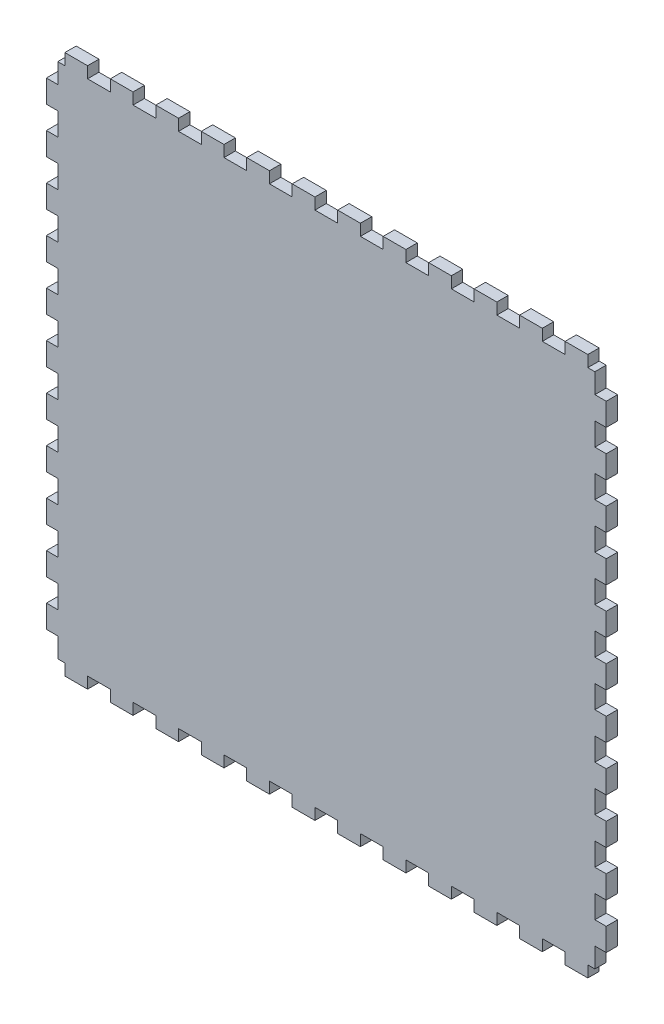
from build123d import *

# Parameters (mm, degrees)
BOSS_EXTRUDE1_DEPTH = 5.715


with BuildPart() as part:
    # Model → Boss-Extrude1 (new body)
    with BuildSketch(Plane.XY):
        Polygon((584.688856535, 28.575245224), (588.246340911, 28.575245224), (588.246340911, 22.860238699), (599.673519312, 22.860238699), (599.673519312, 28.575245224), (611.104241025, 28.575245224), (611.104241025, 22.860238699), (622.534962737, 22.860238699), (622.534962737, 28.575245224), (633.965684449, 28.575245224), (633.965684449, 22.860238699), (645.396406161, 22.860238699), (645.396406161, 28.575245224), (656.823584562, 28.575245224), (656.823584562, 22.860238699), (668.254306275, 22.860238699), (668.254306275, 28.575245224), (679.685027987, 28.575245224), (679.685027987, 22.860238699), (691.115749699, 22.860238699), (691.115749699, 28.575245224), (702.546471411, 28.575245224), (702.546471411, 22.860238699), (713.973649812, 22.860238699), (713.973649812, 28.575245224), (725.404371525, 28.575245224), (725.404371525, 22.860238699), (736.835093237, 22.860238699), (736.835093237, 28.575245224), (748.265814949, 28.575245224), (748.265814949, 22.860238699), (759.696536661, 22.860238699), (759.696536661, 28.575245224), (771.123715063, 28.575245224), (771.123715063, 22.860238699), (782.554436775, 22.860238699), (782.554436775, 28.575245224), (793.985158487, 28.575245224), (793.985158487, 22.860238699), (805.415880199, 22.860238699), (805.415880199, 28.575245224), (816.846601911, 28.575245224), (816.846601911, 22.860238699), (828.273780313, 22.860238699), (828.273780313, 28.575245224), (839.704502025, 28.575245224), (839.704502025, 22.860238699), (851.135223737, 22.860238699), (851.135223737, 28.575245224), (854.689164803, 28.575245224), (854.689164803, 38.560083395), (860.404525659, 38.560083395), (860.404525659, 49.990096445), (854.689164803, 49.990096445), (854.689164803, 61.420109495), (860.404525659, 61.420109495), (860.404525659, 72.850122545), (854.689164803, 72.850122545), (854.689164803, 84.280135595), (860.404525659, 84.280135595), (860.404525659, 95.710148645), (854.689164803, 95.710148645), (854.689164803, 107.140161695), (860.404525659, 107.140161695), (860.404525659, 118.570174745), (854.689164803, 118.570174745), (854.689164803, 130.000187795), (860.404525659, 130.000187795), (860.404525659, 141.430200846), (854.689164803, 141.430200846), (854.689164803, 152.860213896), (860.404525659, 152.860213896), (860.404525659, 164.290226946), (854.689164803, 164.290226946), (854.689164803, 175.720239996), (860.404525659, 175.720239996), (860.404525659, 187.150253046), (854.689164803, 187.150253046), (854.689164803, 198.580266096), (860.404525659, 198.580266096), (860.404525659, 210.010279146), (854.689164803, 210.010279146), (854.689164803, 221.440292196), (860.404525659, 221.440292196), (860.404525659, 232.870305246), (854.689164803, 232.870305246), (854.689164803, 244.300318296), (860.404525659, 244.300318296), (860.404525659, 255.730331346), (854.689164803, 255.730331346), (854.689164803, 267.160344396), (860.404525659, 267.160344396), (860.404525659, 278.590357446), (854.689164803, 278.590357446), (854.689164803, 288.575408216), (851.135223737, 288.575408216), (851.135223737, 294.290414741), (839.704502025, 294.290414741), (839.704502025, 288.575408216), (828.273780313, 288.575408216), (828.273780313, 294.290414741), (816.846601911, 294.290414741), (816.846601911, 288.575408216), (805.415880199, 288.575408216), (805.415880199, 294.290414741), (793.985158487, 294.290414741), (793.985158487, 288.575408216), (782.554436775, 288.575408216), (782.554436775, 294.290414741), (771.123715063, 294.290414741), (771.123715063, 288.575408216), (759.696536661, 288.575408216), (759.696536661, 294.290414741), (748.265814949, 294.290414741), (748.265814949, 288.575408216), (736.835093237, 288.575408216), (736.835093237, 294.290414741), (725.404371525, 294.290414741), (725.404371525, 288.575408216), (713.973649812, 288.575408216), (713.973649812, 294.290414741), (702.546471411, 294.290414741), (702.546471411, 288.575408216), (691.115749699, 288.575408216), (691.115749699, 294.290414741), (679.685027987, 294.290414741), (679.685027987, 288.575408216), (668.254306275, 288.575408216), (668.254306275, 294.290414741), (656.823584562, 294.290414741), (656.823584562, 288.575408216), (645.396406161, 288.575408216), (645.396406161, 294.290414741), (633.965684449, 294.290414741), (633.965684449, 288.575408216), (622.534962737, 288.575408216), (622.534962737, 294.290414741), (611.104241025, 294.290414741), (611.104241025, 288.575408216), (599.673519312, 288.575408216), (599.673519312, 294.290414741), (588.246340911, 294.290414741), (588.246340911, 288.575408216), (584.688856535, 288.575408216), (584.688856535, 278.590357446), (578.973495678, 278.590357446), (578.973495678, 267.160344396), (584.688856535, 267.160344396), (584.688856535, 255.730331346), (578.973495678, 255.730331346), (578.973495678, 244.300318296), (584.688856535, 244.300318296), (584.688856535, 232.870305246), (578.973495678, 232.870305246), (578.973495678, 221.440292196), (584.688856535, 221.440292196), (584.688856535, 210.010279146), (578.973495678, 210.010279146), (578.973495678, 198.580266096), (584.688856535, 198.580266096), (584.688856535, 187.150253046), (578.973495678, 187.150253046), (578.973495678, 175.720239996), (584.688856535, 175.720239996), (584.688856535, 164.290226946), (578.973495678, 164.290226946), (578.973495678, 152.860213896), (584.688856535, 152.860213896), (584.688856535, 141.430200846), (578.973495678, 141.430200846), (578.973495678, 130.000187795), (584.688856535, 130.000187795), (584.688856535, 118.570174745), (578.973495678, 118.570174745), (578.973495678, 107.140161695), (584.688856535, 107.140161695), (584.688856535, 95.710148645), (578.973495678, 95.710148645), (578.973495678, 84.280135595), (584.688856535, 84.280135595), (584.688856535, 72.850122545), (578.973495678, 72.850122545), (578.973495678, 61.420109495), (584.688856535, 61.420109495), (584.688856535, 49.990096445), (578.973495678, 49.990096445), (578.973495678, 38.560083395), (584.688856535, 38.560083395), align=None)
    extrude(amount=BOSS_EXTRUDE1_DEPTH)


solid = part.part
